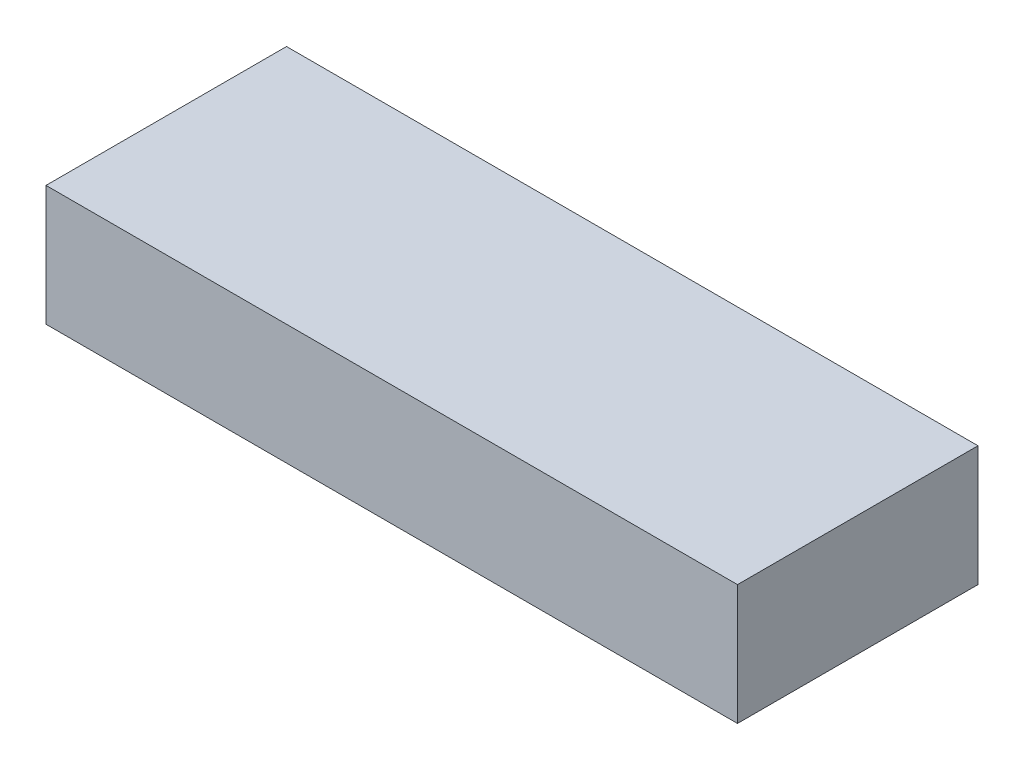
from build123d import *

# Parameters (mm, degrees)
SKETCH1_W           = 146.05
SKETCH1_H           = 50.8
BOSS_EXTRUDE1_DEPTH = 25.4


with BuildPart() as part:
    # Sketch1 → Boss-Extrude1 (new body)
    with BuildSketch(Plane(origin=(0, 0, 0), x_dir=(1, 0, 0), z_dir=(0, 1, 0))):
        with Locations((73.025, 0)):
            Rectangle(SKETCH1_W, SKETCH1_H)
    extrude(amount=BOSS_EXTRUDE1_DEPTH)


solid = part.part
